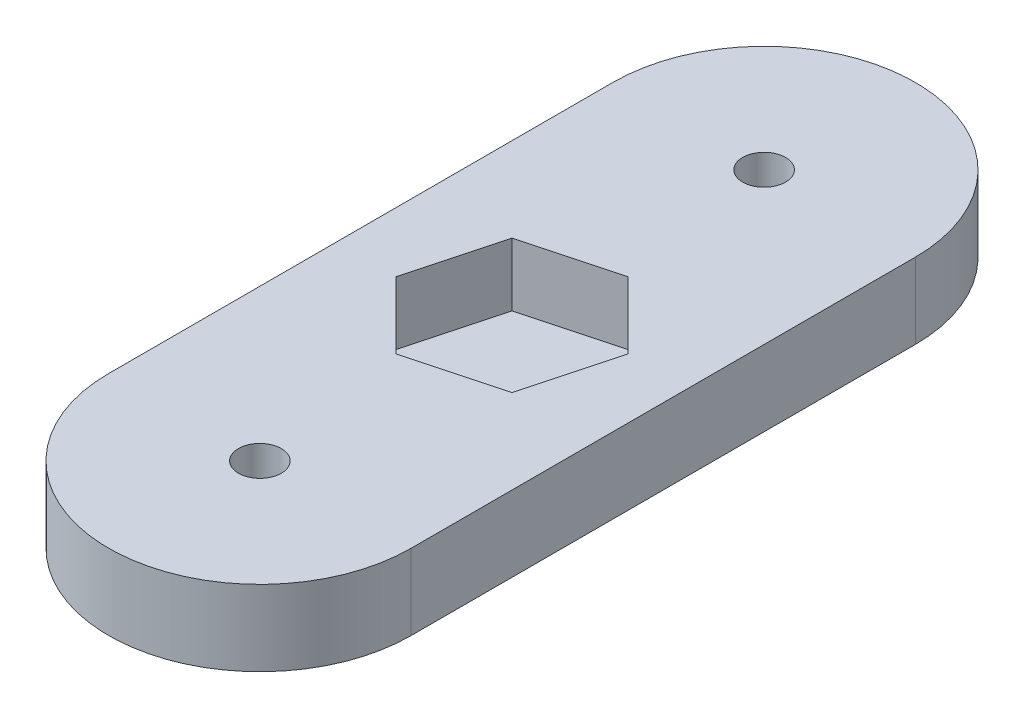
from build123d import *

# Parameters (mm, degrees)
SKETCH1_R           = 1.7
BOSS_EXTRUDE1_DEPTH = 6
CUT_EXTRUDE1_DEPTH  = 5


with BuildPart() as part:
    # Sketch1 → Boss-Extrude1 (new body)
    with BuildSketch(Plane(origin=(0, 0, 0), x_dir=(1, 0, 0), z_dir=(0, 1, 0))):
        with BuildLine():
            Line((-12, 0), (-12, 40))
            ThreePointArc((-12, 40), (0, 52), (12, 40))
            Line((12, 40), (12, 0))
            ThreePointArc((12, 0), (0, -12), (-12, 0))
        make_face()
        with Locations((0, 40)):
            Circle(SKETCH1_R, mode=Mode.SUBTRACT)
        Circle(SKETCH1_R, mode=Mode.SUBTRACT)
    extrude(amount=BOSS_EXTRUDE1_DEPTH)

    # Sketch2 → Cut-Extrude1 (cut)
    with BuildSketch(Plane(origin=(0, 6, 0), x_dir=(1, 0, 0), z_dir=(0, 1, 0))):
        Polygon((5.307227776, 14.692772224), (7.249807966, 21.94258019), (1.94258019, 27.249807966), (-5.307227776, 25.307227776), (-7.249807966, 18.05741981), (-1.94258019, 12.750192034), align=None)
    extrude(amount=-CUT_EXTRUDE1_DEPTH, mode=Mode.SUBTRACT)


solid = part.part
